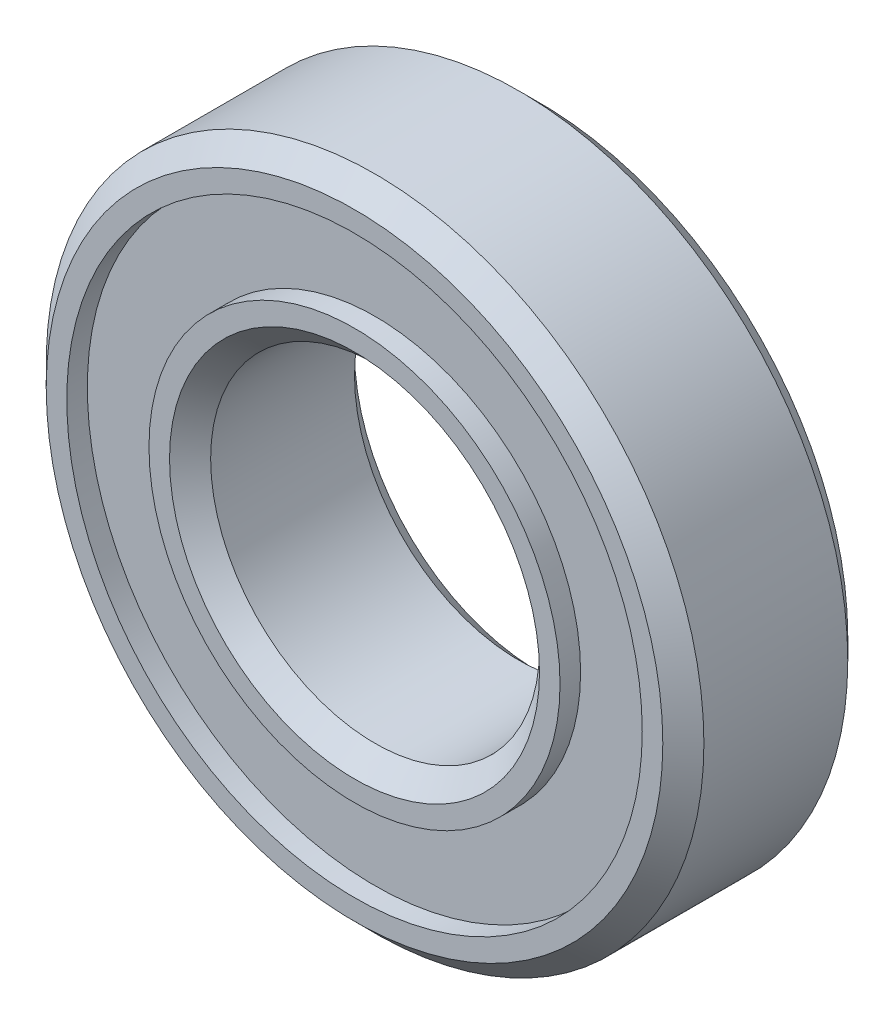
from build123d import *

# Parameters (mm, degrees)
SKETCH1_R           = 8
SKETCH1_R_2         = 4
BOSS_EXTRUDE1_DEPTH = 4.5
CHAMFER1_SIZE       = 0.5
SKETCH2_R           = 7
SKETCH2_R_2         = 5
CUT_EXTRUDE1_DEPTH  = 0.5
SKETCH3_R           = 7
SKETCH3_R_2         = 5
CUT_EXTRUDE2_DEPTH  = 0.5


with BuildPart() as part:
    # Sketch1 → Boss-Extrude1 (new body)
    with BuildSketch(Plane.XY):
        Circle(SKETCH1_R)
        Circle(SKETCH1_R_2, mode=Mode.SUBTRACT)
    extrude(amount=BOSS_EXTRUDE1_DEPTH)

    # Chamfer1
    chamfer1_edges = [part.edges().sort_by_distance(p)[0] for p in [
        (-8, 0, 0),
        (-8, 0, 4.5),
        (-4, 0, 0),
        (-4, 0, 4.5),
    ]]
    chamfer(chamfer1_edges, length=CHAMFER1_SIZE)

    # Sketch2 → Cut-Extrude1 (cut)
    with BuildSketch(Plane.XY):
        Circle(SKETCH2_R)
        Circle(SKETCH2_R_2, mode=Mode.SUBTRACT)
    extrude(amount=CUT_EXTRUDE1_DEPTH, mode=Mode.SUBTRACT)

    # Sketch3 → Cut-Extrude2 (cut)
    with BuildSketch(Plane.XY.offset(4.5)):
        Circle(SKETCH3_R)
        Circle(SKETCH3_R_2, mode=Mode.SUBTRACT)
    extrude(amount=-CUT_EXTRUDE2_DEPTH, mode=Mode.SUBTRACT)


solid = part.part
